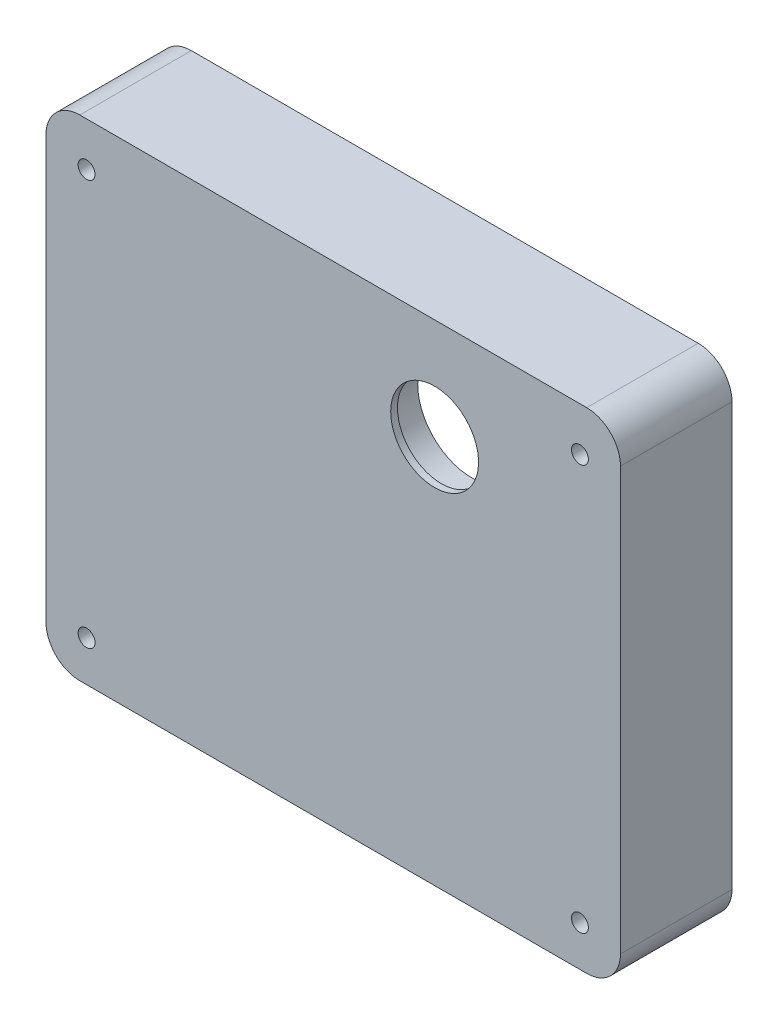
from build123d import *

# Parameters (mm, degrees)
BOSS_EXTRUDE1_DEPTH = 33
CUT_EXTRUDE1_DEPTH  = 22
SKETCH3_R           = 13
CUT_EXTRUDE2_DEPTH  = 8
SKETCH4_R           = 10.5
CUT_EXTRUDE3_DEPTH  = 1
SKETCH5_R           = 16
CUT_EXTRUDE4_DEPTH  = 9
SKETCH6_R           = 13
CUT_EXTRUDE5_DEPTH  = 3
FILLET1_R           = 2
FILLET2_R           = 0.2
M6_TAPPED_HOLE1_D   = 5


with BuildPart() as part:
    # Sketch1 → Boss-Extrude1 (new body)
    with BuildSketch(Plane.XY):
        with BuildLine():
            Line((-105, 90), (45, 90))
            ThreePointArc((45, 90), (52.071067812, 87.071067812), (55, 80))
            Line((55, 80), (55, -45))
            ThreePointArc((55, -45), (52.071067812, -52.071067812), (45, -55))
            Line((45, -55), (-105, -55))
            ThreePointArc((-105, -55), (-112.071067812, -52.071067812), (-115, -45))
            Line((-115, -45), (-115, 80))
            ThreePointArc((-115, 80), (-112.071067812, 87.071067812), (-105, 90))
        make_face()
    extrude(amount=BOSS_EXTRUDE1_DEPTH)

    # Sketch2 → Cut-Extrude1 (cut)
    with BuildSketch(Plane.XY):
        with BuildLine():
            Line((-60, -50), (0, -50))
            ThreePointArc((0, -50), (35.355339059, -35.355339059), (50, 0))
            Line((50, 0), (50, 54))
            ThreePointArc((50, 54), (48.242640687, 58.242640687), (44, 60))
            Line((44, 60), (30.413812651, 60))
            ThreePointArc((30.413812651, 60), (26.603808841, 61.364930317), (24.527268267, 64.838709677))
            ThreePointArc((24.527268267, 64.838709677), (0, 85), (-24.527268267, 64.838709677))
            ThreePointArc((-24.527268267, 64.838709677), (-26.603808841, 61.364930317), (-30.413812651, 60))
            Line((-30.413812651, 60), (-104, 60))
            ThreePointArc((-104, 60), (-108.242640687, 58.242640687), (-110, 54))
            Line((-110, 54), (-110, 0))
            ThreePointArc((-110, 0), (-95.355339059, -35.355339059), (-60, -50))
        make_face()
    extrude(amount=CUT_EXTRUDE1_DEPTH, mode=Mode.SUBTRACT)

    # Sketch3 → Cut-Extrude2 (cut)
    with BuildSketch(Plane(origin=(0, 0, 22), x_dir=(-1, 0, 0), z_dir=(0, 0, -1))):
        Circle(SKETCH3_R)
        with Locations((60, 0)):
            Circle(SKETCH3_R)
    extrude(amount=-CUT_EXTRUDE2_DEPTH, mode=Mode.SUBTRACT)

    # Sketch4 → Cut-Extrude3 (cut)
    with BuildSketch(Plane(origin=(0, 0, 30), x_dir=(-1, 0, 0), z_dir=(0, 0, -1))):
        Circle(SKETCH4_R)
        with Locations((60, 0)):
            Circle(SKETCH4_R)
    extrude(amount=-CUT_EXTRUDE3_DEPTH, mode=Mode.SUBTRACT)

    # Sketch5 → Cut-Extrude4 (cut)
    with BuildSketch(Plane(origin=(0, 0, 22), x_dir=(-1, 0, 0), z_dir=(0, 0, -1))):
        with Locations((0, 60)):
            Circle(SKETCH5_R)
    extrude(amount=-CUT_EXTRUDE4_DEPTH, mode=Mode.SUBTRACT)

    # Sketch6 → Cut-Extrude5 (cut, through all)
    with BuildSketch(Plane(origin=(0, 0, 31), x_dir=(-1, 0, 0), z_dir=(0, 0, -1))):
        with Locations((0, 60)):
            Circle(SKETCH6_R)
    extrude(amount=-CUT_EXTRUDE5_DEPTH, mode=Mode.SUBTRACT)

    # Fillet1
    fillet1_edges = [part.edges().sort_by_distance(p)[0] for p in [
        (-95.355339059, -35.355339059, 22),
        (-30, -50, 22),
        (35.355339059, -35.355339059, 22),
        (50, 27, 22),
        (48.242640687, 58.242640687, 22),
        (37.206906326, 60, 22),
        (26.603808841, 61.364930317, 22),
        (0, 85, 22),
        (-26.603808841, 61.364930317, 22),
        (-67.206906326, 60, 22),
        (-108.242640687, 58.242640687, 22),
        (-110, 27, 22),
    ]]
    fillet(fillet1_edges, radius=FILLET1_R)

    # Fillet2
    fillet2_edges = [part.edges().sort_by_distance(p)[0] for p in [
        (13, 0, 30),
        (-47, 0, 30),
        (16, 60, 31),
    ]]
    fillet(fillet2_edges, radius=FILLET2_R)

    # M6 Tapped Hole1 (through all)
    with Locations(Plane(origin=(0, 0, 0), x_dir=(-1, 0, 0), z_dir=(0, 0, -1))):
        with Locations((103, 77), (-43, 77), (-43, -43), (103, -43)):
            Hole(M6_TAPPED_HOLE1_D / 2)


solid = part.part
